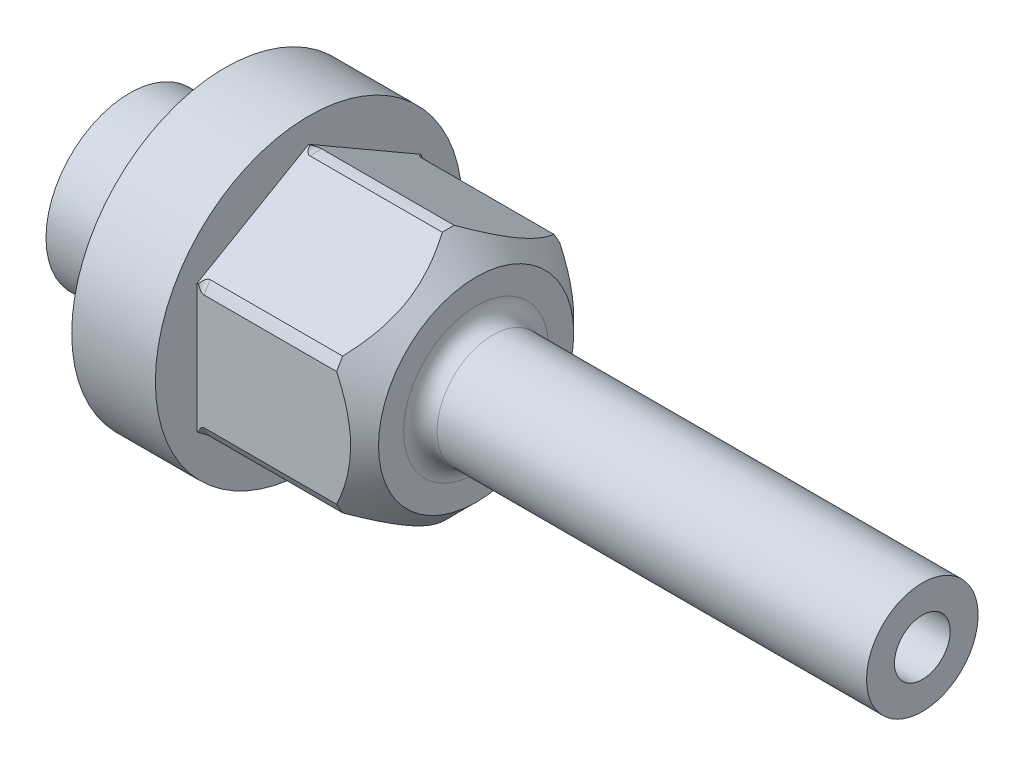
from build123d import *

# Parameters (mm, degrees)
CUT_EXTRUDE1_START = 3
SKETCH2_OUTSIDE_W  = 19.582
SKETCH2_OUTSIDE_H  = 19.582
CUT_EXTRUDE1_DEPTH = 10


with BuildPart() as part:
    # Sketch1 → Revolve1 (revolve)
    with BuildSketch(Plane.XY):
        with BuildLine():
            Line((0, 5.5), (0, 4.75))
            Line((0, 4.75), (0.25, 4.5))
            Line((0.25, 4.5), (1.15, 4.5))
            ThreePointArc((1.15, 4.5), (1.326776695, 4.426776695), (1.4, 4.25))
            Line((1.4, 4.25), (1.4, 3.25))
            ThreePointArc((1.4, 3.25), (1.326776695, 3.073223305), (1.15, 3))
            Line((1.15, 3), (-3.422649731, 3))
            Line((-3.422649731, 3), (-4, 2))
            Line((-4, 2), (-4, 1))
            Line((-4, 1), (25, 1))
            Line((25, 1), (25, 2))
            Line((25, 2), (9.6, 2))
            ThreePointArc((9.6, 2), (9.175735931, 2.175735931), (9, 2.6))
            Line((9, 2.6), (9, 3.5))
            Line((9, 3.5), (8, 4.5))
            Line((8, 4.5), (3.25, 4.5))
            ThreePointArc((3.25, 4.5), (3.073223305, 4.573223305), (3, 4.75))
            Line((3, 4.75), (3, 5.5))
            Line((3, 5.5), (0, 5.5))
        make_face()
    revolve(axis=Axis((-88.99, 0, 0), (1, 0, 0)))

    # Sketch2 outside → Cut-Extrude1 (cut)
    with BuildSketch(Plane(origin=(0, 0, 0), x_dir=(0, 0, -1), z_dir=(1, 0, 0)).offset(CUT_EXTRUDE1_START)):
        Rectangle(SKETCH2_OUTSIDE_W, SKETCH2_OUTSIDE_H)
        Polygon((0, 4.618802154), (-4, 2.309401077), (-4, -2.309401077), (0, -4.618802154), (4, -2.309401077), (4, 2.309401077), align=None, mode=Mode.SUBTRACT)
    extrude(amount=CUT_EXTRUDE1_DEPTH, mode=Mode.SUBTRACT)


solid = part.part
